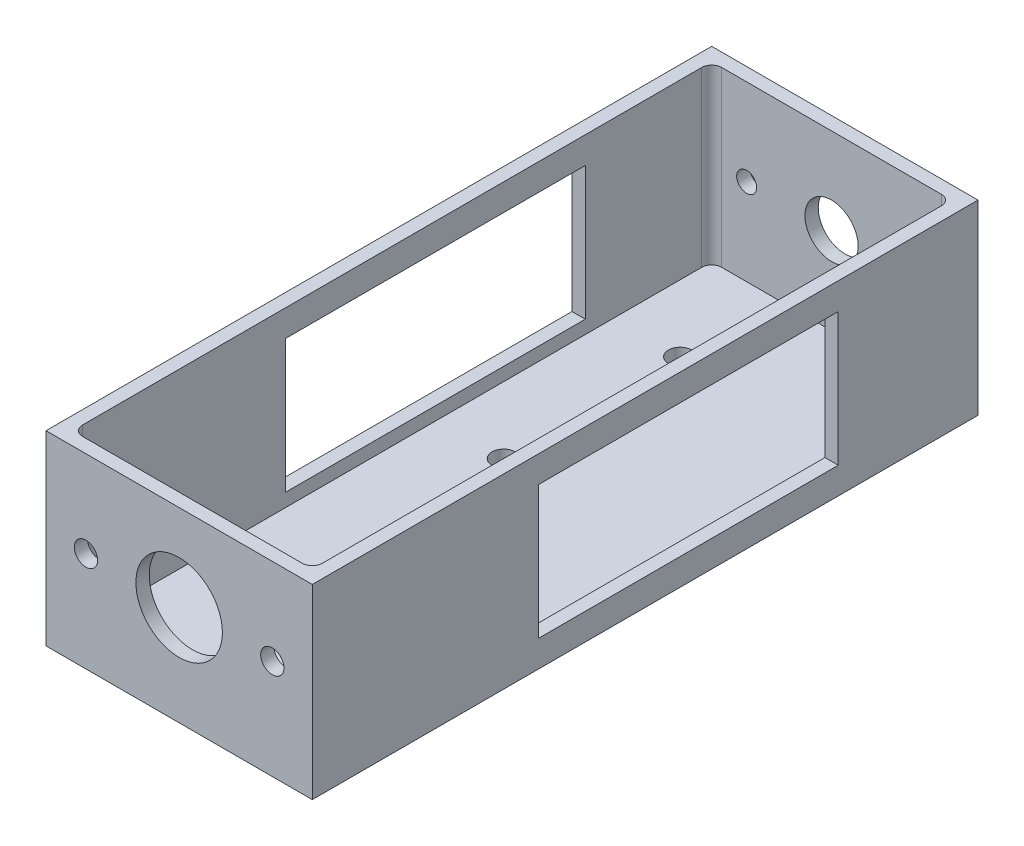
from build123d import *

# Parameters (mm, degrees)
SKETCH_1_W          = 80
SKETCH_1_H          = 56
EXTRUDE_1_DEPTH     = 200
CUT_EXTRUDE_1_DEPTH = 52
SKETCH_3_R          = 3.5
SKETCH_3_R_2        = 13
CUT_EXTRUDE_2_DEPTH = 10
SKETCH_5_R          = 8
SKETCH_5_R_2        = 3
CUT_EXTRUDE_4_DEPTH = 10
SKETCH_6_R          = 3.500000002
SKETCH_6_R_2        = 3.5
CUT_EXTRUDE_5_DEPTH = 10
SKETCH_7_W          = 90
SKETCH_7_H          = 40
CUT_EXTRUDE_6_DEPTH = 81


with BuildPart() as part:
    # 草图1 → 凸台-拉伸1 (new body)
    with BuildSketch(Plane.XY):
        Rectangle(SKETCH_1_W, SKETCH_1_H)
    extrude(amount=-EXTRUDE_1_DEPTH)

    # 草图2 → 切除-拉伸1 (cut)
    with BuildSketch(Plane(origin=(0, 28, 0), x_dir=(1, 0, 0), z_dir=(0, 1, 0))):
        with BuildLine():
            ThreePointArc((-36, 193), (-35.121320344, 195.121320344), (-33, 196))
            Line((-33, 196), (33, 196))
            ThreePointArc((33, 196), (35.121320344, 195.121320344), (36, 193))
            Line((36, 193), (36, 7))
            ThreePointArc((36, 7), (35.121320344, 4.878679656), (33, 4))
            Line((33, 4), (-33, 4))
            ThreePointArc((-33, 4), (-35.121320344, 4.878679656), (-36, 7))
            Line((-36, 7), (-36, 193))
        make_face()
    extrude(amount=-CUT_EXTRUDE_1_DEPTH, mode=Mode.SUBTRACT)

    # 草图3 → 切除-拉伸2 (cut)
    with BuildSketch(Plane.XY):
        with Locations((-28, 2)):
            Circle(SKETCH_3_R)
        with Locations((0, 2)):
            Circle(SKETCH_3_R_2)
        with Locations((28, 2)):
            Circle(SKETCH_3_R)
    extrude(amount=-CUT_EXTRUDE_2_DEPTH, mode=Mode.SUBTRACT)

    # 草图5 → 切除-拉伸4 (cut)
    with BuildSketch(Plane(origin=(0, 0, -200), x_dir=(-1, 0, 0), z_dir=(0, 0, -1))):
        with Locations((0, 2)):
            Circle(SKETCH_5_R)
        with Locations((25.5, 2)):
            Circle(SKETCH_5_R_2)
        with Locations((-25.5, 2)):
            Circle(SKETCH_5_R_2)
    extrude(amount=-CUT_EXTRUDE_4_DEPTH, mode=Mode.SUBTRACT)

    # 草图6 → 切除-拉伸5 (cut)
    with BuildSketch(Plane(origin=(0, -24, 0), x_dir=(1, 0, 0), z_dir=(0, 1, 0))):
        with Locations((-16, 166.5)):
            Circle(SKETCH_6_R)
        with Locations((-16, 113.5)):
            Circle(SKETCH_6_R_2)
    extrude(amount=-CUT_EXTRUDE_5_DEPTH, mode=Mode.SUBTRACT)

    # 草图7 → 切除-拉伸6 (cut, through all)
    with BuildSketch(Plane.ZY.offset(40)):
        with Locations((-113.014709347, 0)):
            Rectangle(SKETCH_7_W, SKETCH_7_H)
    extrude(amount=-CUT_EXTRUDE_6_DEPTH, mode=Mode.SUBTRACT)


solid = part.part
